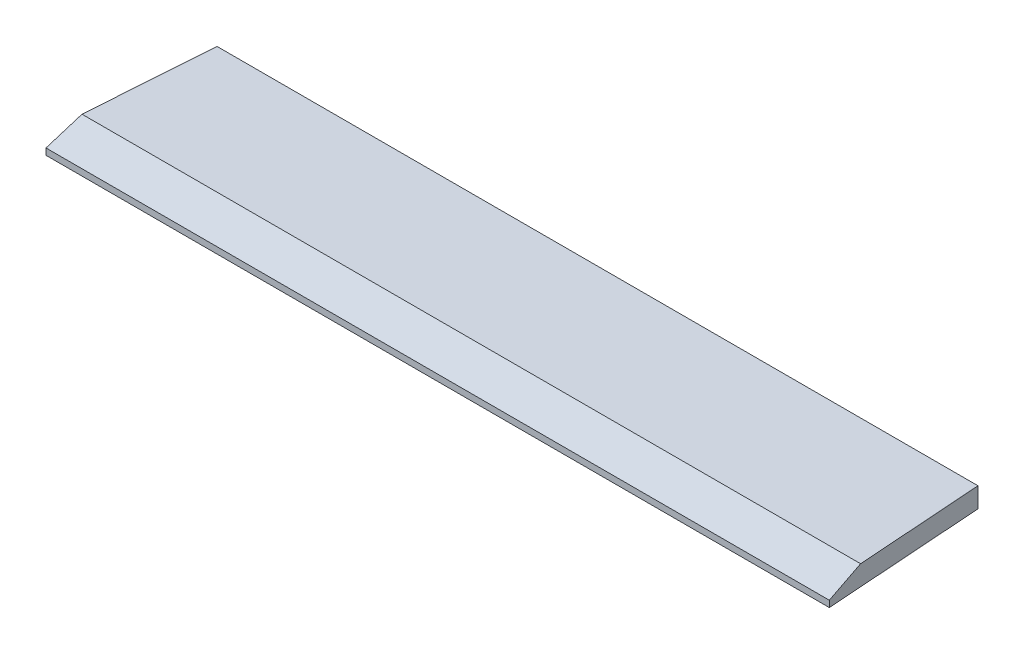
from build123d import *

# Parameters (mm, degrees)
EXTRUDE1_DEPTH          = 490
CUT_EXTRUDE1_DEPTH      = 11
CUT_EXTRUDE1_DEPTH_BACK = 16
CUT_EXTRUDE2_DEPTH      = 11
CUT_EXTRUDE2_DEPTH_BACK = 16


with BuildPart() as part:
    # Sketch1 → Extrude1 (new body, symmetric)
    with BuildSketch(Plane(origin=(0, 0, 0), x_dir=(0, 0, -1), z_dir=(1, 0, 0))):
        Polygon((-200, -7), (-200, -15), (0, -15), (0, 10), (-157.923523492, 10), align=None)
    extrude(amount=EXTRUDE1_DEPTH, both=True)

    # Sketch2 → Cut-Extrude1 (cut, two sides)
    with BuildSketch(Plane(origin=(0, 0, 0), x_dir=(1, 0, 0), z_dir=(0, 1, 0))) as cut_extrude1_sk:
        Polygon((-335.776225586, 2005.502726748), (-476.014637611, 0), (-490, -200), (-630.238412025, -2205.502726748), (-4641.243865521, -1925.025902697), (-4346.781679081, 2285.979550799), align=None)
    extrude(amount=CUT_EXTRUDE1_DEPTH, mode=Mode.SUBTRACT)
    extrude(cut_extrude1_sk.sketch, amount=-CUT_EXTRUDE1_DEPTH_BACK, mode=Mode.SUBTRACT)

    # Sketch3 → Cut-Extrude2 (cut, two sides)
    with BuildSketch(Plane(origin=(0, 0, 0), x_dir=(1, 0, 0), z_dir=(0, 1, 0))) as cut_extrude2_sk:
        Polygon((630.238412025, -2205.502726748), (490, -200), (476.014637611, 0), (335.776225586, 2005.502726748), (4346.781679081, 2285.979550799), (4641.243865521, -1925.025902697), align=None)
    extrude(amount=CUT_EXTRUDE2_DEPTH, mode=Mode.SUBTRACT)
    extrude(cut_extrude2_sk.sketch, amount=-CUT_EXTRUDE2_DEPTH_BACK, mode=Mode.SUBTRACT)


solid = part.part
